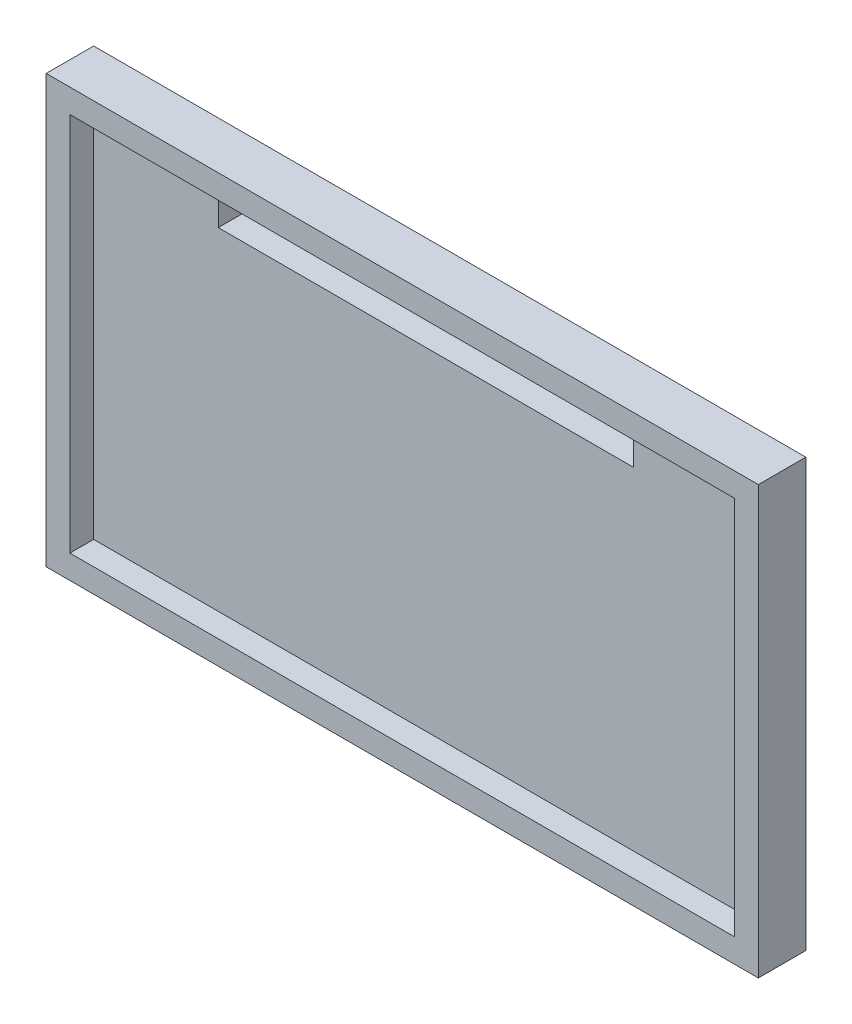
from build123d import *

# Parameters (mm, degrees)
SKETCH_1_W      = 60
SKETCH_1_H      = 36
SKETCH_1_W_2    = 35
SKETCH_1_H_2    = 4
EXTRUDE_1_DEPTH = 2
SKETCH_2_W      = 60
SKETCH_2_H      = 36
SKETCH_2_W_2    = 56
SKETCH_2_H_2    = 32
EXTRUDE_2_DEPTH = 2


with BuildPart() as part:
    # ｽｹｯﾁ1 → ﾎﾞｽ - 押し出し1 (new body)
    with BuildSketch(Plane.XY):
        Rectangle(SKETCH_1_W, SKETCH_1_H)
        with Locations((0, 14)):
            Rectangle(SKETCH_1_W_2, SKETCH_1_H_2, mode=Mode.SUBTRACT)
    extrude(amount=EXTRUDE_1_DEPTH)

    # ｽｹｯﾁ2 → ﾎﾞｽ - 押し出し2 (add)
    with BuildSketch(Plane.XY.offset(2)):
        Rectangle(SKETCH_2_W, SKETCH_2_H)
        Rectangle(SKETCH_2_W_2, SKETCH_2_H_2, mode=Mode.SUBTRACT)
    extrude(amount=EXTRUDE_2_DEPTH)


solid = part.part
